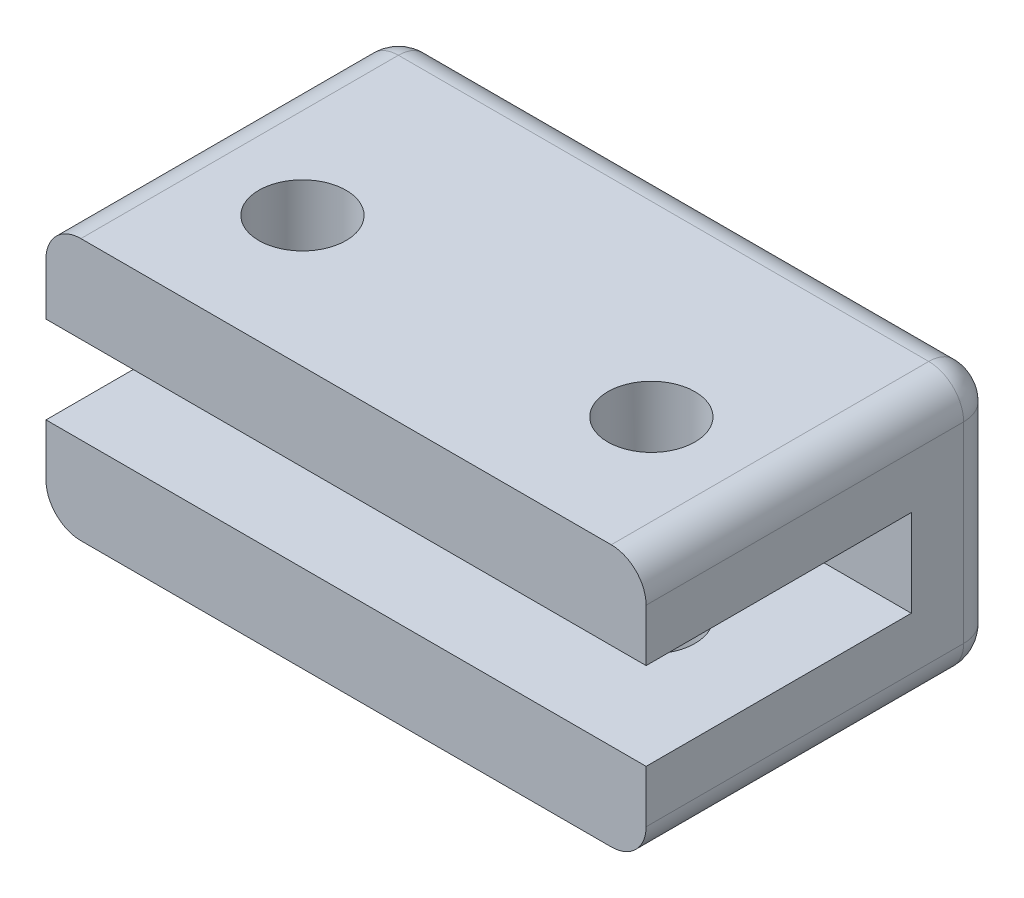
from build123d import *

# Parameters (mm, degrees)
SKETCH1_W           = 2.0955
SKETCH1_H           = 12.7
SKETCH2_W           = 21.844
SKETCH2_H           = 9.525
BOSS_EXTRUDE1_DEPTH = 12.827
FILLET4_R           = 1.27
SKETCH3_W           = 9.652
SKETCH3_H           = 3.175
CUT_EXTRUDE1_DEPTH  = 22.844
SKETCH4_R           = 1.5875
CUT_EXTRUDE2_DEPTH  = 10.525
CUT_EXTRUDE3_REACH  = 14.827
SKETCH5_R           = 1.1303
SKETCH6_W           = 4.191
SKETCH6_H           = 12.7
CUT_EXTRUDE4_DEPTH  = 10.525


with BuildPart() as part:
    # Sketch1 → Revolve1 (revolve)
    with BuildSketch(Plane(origin=(0, 0, 0), x_dir=(1, 0, 0), z_dir=(0, 1, 0))):
        with Locations((1.04775, 6.35)):
            Rectangle(SKETCH1_W, SKETCH1_H)
    revolve(axis=Axis((0, 0, -12.7), (0, 0, 1)))

    # Sketch2 → Boss-Extrude1 (add)
    with BuildSketch(Plane.XY):
        Rectangle(SKETCH2_W, SKETCH2_H)
    extrude(amount=BOSS_EXTRUDE1_DEPTH)

    # Fillet4
    fillet4_edges = [part.edges().sort_by_distance(p)[0] for p in [
        (10.922, -4.7625, 6.4135),
        (0, 4.7625, 0),
        (10.922, 4.7625, 6.4135),
        (-10.922, 0, 0),
        (-10.922, 4.7625, 6.4135),
        (0, -4.7625, 0),
        (-10.922, -4.7625, 6.4135),
        (10.922, 0, 0),
    ]]
    fillet(fillet4_edges, radius=FILLET4_R)

    # Sketch3 → Cut-Extrude1 (cut, through all)
    with BuildSketch(Plane.ZY.offset(10.922)):
        with Locations((8.001, 0)):
            Rectangle(SKETCH3_W, SKETCH3_H)
    extrude(amount=-CUT_EXTRUDE1_DEPTH, mode=Mode.SUBTRACT)

    # Sketch4 → Cut-Extrude2 (cut, through all)
    with BuildSketch(Plane(origin=(0, 4.7625, 0), x_dir=(1, 0, 0), z_dir=(0, 1, 0))):
        with Locations((-6.35, -8.0645)):
            Circle(SKETCH4_R)
        with Locations((6.35, -8.0645)):
            Circle(SKETCH4_R)
    extrude(amount=-CUT_EXTRUDE2_DEPTH, mode=Mode.SUBTRACT)

    # Sketch5 → Cut-Extrude3 (cut, up to next)
    with BuildSketch(Plane(origin=(0, 0, 0), x_dir=(-1, 0, 0), z_dir=(0, 0, -1)), mode=Mode.PRIVATE) as cut_extrude3_sk1:
        Circle(SKETCH5_R)
    cut_extrude3_tool1 = extrude(cut_extrude3_sk1.sketch, amount=-CUT_EXTRUDE3_REACH, mode=Mode.PRIVATE) & part.part
    add(cut_extrude3_tool1.solids().sort_by_distance((0, 0, 0))[0], mode=Mode.SUBTRACT)

    # Sketch6 → Cut-Extrude4 (cut, through all)
    with BuildSketch(Plane(origin=(0, 4.7625, 0), x_dir=(1, 0, 0), z_dir=(0, 1, 0))):
        with Locations((0, 6.35)):
            Rectangle(SKETCH6_W, SKETCH6_H)
    extrude(amount=-CUT_EXTRUDE4_DEPTH, mode=Mode.SUBTRACT)


solid = part.part
